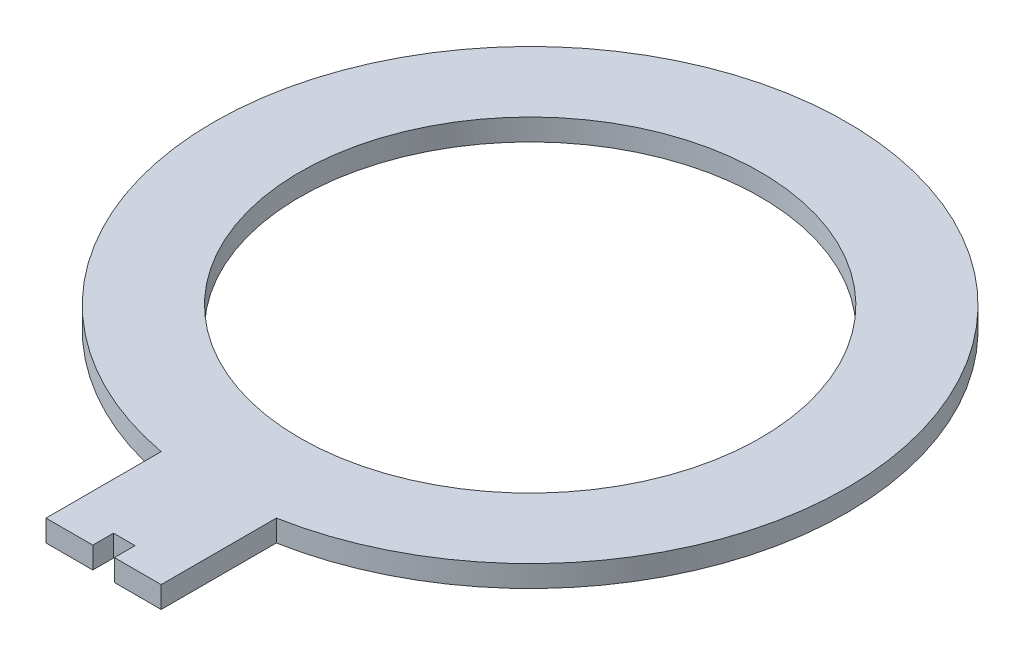
from build123d import *

# Parameters (mm, degrees)
SKETCH1_R           = 50.8
BOSS_EXTRUDE1_DEPTH = 4.7625


with BuildPart() as part:
    # Sketch1 → Boss-Extrude1 (new body)
    with BuildSketch(Plane(origin=(0, 0, 0), x_dir=(1, 0, 0), z_dir=(0, 1, 0))):
        with BuildLine():
            Line((12.7, -94.085751798), (12.7, -68.685751798))
            ThreePointArc((12.7, -68.685751798), (0, 69.85), (-12.7, -68.685751798))
            Line((-12.7, -68.685751798), (-12.7, -94.085751798))
            Line((-12.7, -94.085751798), (-2.38125, -94.085751798))
            Line((-2.38125, -94.085751798), (-2.38125, -89.521371798))
            Line((-2.38125, -89.521371798), (2.38125, -89.521371798))
            Line((2.38125, -89.521371798), (2.38125, -94.085751798))
            Line((2.38125, -94.085751798), (12.7, -94.085751798))
        make_face()
        Circle(SKETCH1_R, mode=Mode.SUBTRACT)
    extrude(amount=BOSS_EXTRUDE1_DEPTH)


solid = part.part
